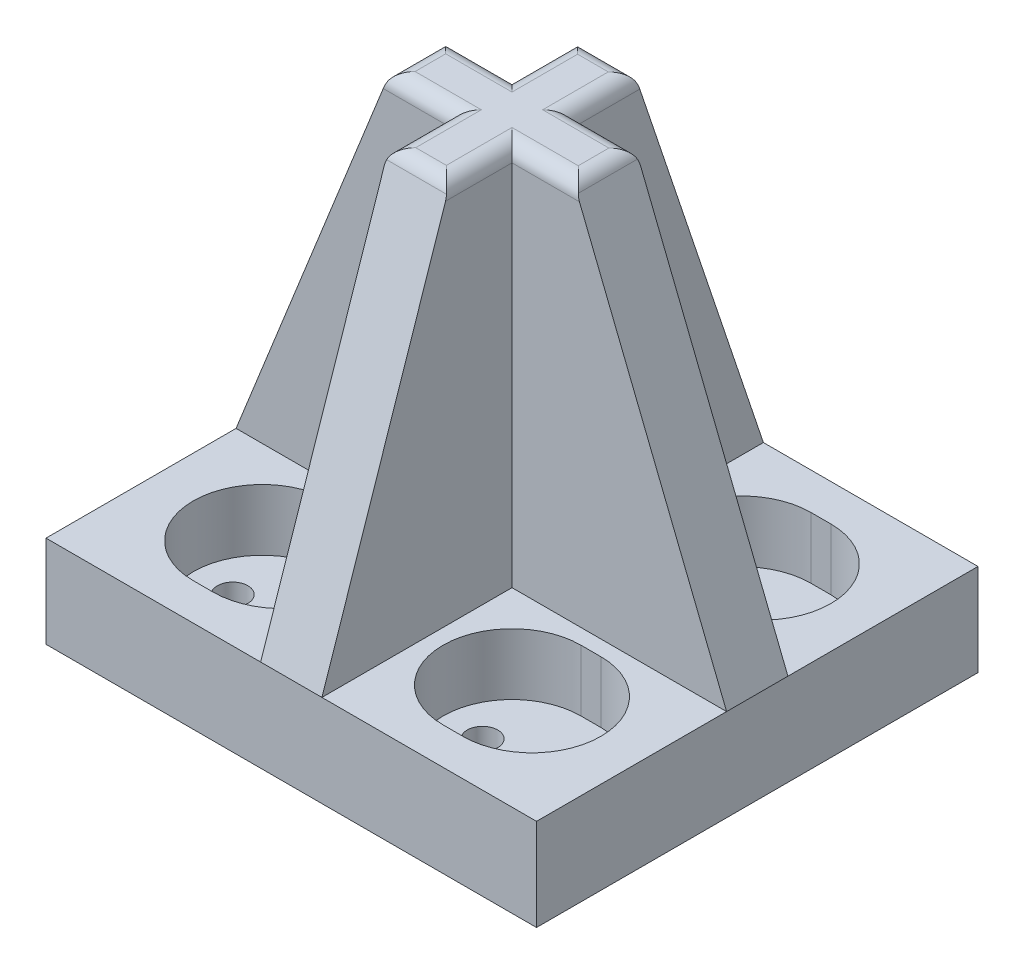
from build123d import *

# Parameters (mm, degrees)
SKETCH1_W                = 8
SKETCH1_H                = 7.2
BOSS_EXTRUDE1_DEPTH      = 3
CUT_EXTRUDE1_DEPTH       = 2
SKETCH3_R                = 0.49811532
CUT_EXTRUDE2_DEPTH       = 2
BOSS_EXTRUDE2_DEPTH      = 1
BOSS_EXTRUDE3_DEPTH      = 1
MIRROR22_COPY_1_SKETCH_W = 8
MIRROR22_COPY_1_SKETCH_H = 7.2
MIRROR22_COPY_1_DEPTH    = 3
MIRROR22_COPY_2_DEPTH    = 2
MIRROR22_COPY_3_SKETCH_R = 0.49811532
MIRROR22_COPY_3_DEPTH    = 2
MIRROR22_COPY_4_DEPTH    = 1
MIRROR22_COPY_5_DEPTH    = 1
MIRROR22_COPY_6_DEPTH    = 1
MIRROR22_COPY_7_DEPTH    = 1
FILLET6_R                = 0.5


with BuildPart() as part:
    # Sketch1 → Boss-Extrude1 (new body)
    with BuildSketch(Plane(origin=(0, 0, 0), x_dir=(1, 0, 0), z_dir=(0, 1, 0))):
        with Locations((4, -3.6)):
            Rectangle(SKETCH1_W, SKETCH1_H)
    boss_extrude1 = extrude(amount=BOSS_EXTRUDE1_DEPTH)

    # Sketch2 → Cut-Extrude1 (cut)
    with BuildSketch(Plane(origin=(0, 3, 0), x_dir=(1, 0, 0), z_dir=(0, 1, 0))):
        with BuildLine():
            Line((3.75, -1.5), (4.4, -1.5))
            ThreePointArc((4.4, -1.5), (6.65, -3.75), (4.4, -6))
            Line((4.4, -6), (3.75, -6))
            ThreePointArc((3.75, -6), (1.5, -3.75), (3.75, -1.5))
        make_face()
    cut_extrude1 = extrude(amount=-CUT_EXTRUDE1_DEPTH, mode=Mode.SUBTRACT)

    # Sketch3 → Cut-Extrude2 (cut, through all)
    with BuildSketch(Plane(origin=(0, 1, 0), x_dir=(1, 0, 0), z_dir=(0, 1, 0))):
        with Locations((2.7875, -3.75)):
            Circle(SKETCH3_R)
        with Locations((5.3625, -3.75)):
            Circle(SKETCH3_R)
    cut_extrude2 = extrude(amount=-CUT_EXTRUDE2_DEPTH, mode=Mode.SUBTRACT)

    # Sketch4 → Boss-Extrude2 (add)
    with BuildSketch(Plane.ZY):
        Polygon((0, 3), (0, 15.5), (3, 15.5), (7.2, 3), align=None)
    boss_extrude2 = extrude(amount=-BOSS_EXTRUDE2_DEPTH)

    # Sketch7 → Boss-Extrude3 (add)
    with BuildSketch(Plane(origin=(0, 0, 0), x_dir=(-1, 0, 0), z_dir=(0, 0, -1))):
        Polygon((0, 15.5), (-3, 15.5), (-8, 3), (0, 3), align=None)
    boss_extrude3 = extrude(amount=-BOSS_EXTRUDE3_DEPTH)

    # Mirror16: Boss-Extrude1, Cut-Extrude1, Cut-Extrude2, Boss-Extrude2, Boss-Extrude3 across plane
    add(boss_extrude1.mirror(Plane(origin=(0, 3, 0), x_dir=(0, 0, 1), z_dir=(1, 0, 0))))
    add(cut_extrude1.mirror(Plane(origin=(0, 3, 0), x_dir=(0, 0, 1), z_dir=(1, 0, 0))), mode=Mode.SUBTRACT)
    add(cut_extrude2.mirror(Plane(origin=(0, 3, 0), x_dir=(0, 0, 1), z_dir=(1, 0, 0))), mode=Mode.SUBTRACT)
    add(boss_extrude2.mirror(Plane(origin=(0, 3, 0), x_dir=(0, 0, 1), z_dir=(1, 0, 0))))
    add(boss_extrude3.mirror(Plane(origin=(0, 3, 0), x_dir=(0, 0, 1), z_dir=(1, 0, 0))))

    # Mirror21: Boss-Extrude1, Cut-Extrude1, Cut-Extrude2, Boss-Extrude2, Boss-Extrude3 across plane
    add(boss_extrude1.mirror(Plane(origin=(0, 3, 0), x_dir=(1, 0, 0), z_dir=(0, 0, 1))))
    add(cut_extrude1.mirror(Plane(origin=(0, 3, 0), x_dir=(1, 0, 0), z_dir=(0, 0, 1))), mode=Mode.SUBTRACT)
    add(cut_extrude2.mirror(Plane(origin=(0, 3, 0), x_dir=(1, 0, 0), z_dir=(0, 0, 1))), mode=Mode.SUBTRACT)
    add(boss_extrude2.mirror(Plane(origin=(0, 3, 0), x_dir=(1, 0, 0), z_dir=(0, 0, 1))))
    add(boss_extrude3.mirror(Plane(origin=(0, 3, 0), x_dir=(1, 0, 0), z_dir=(0, 0, 1))))

    # Mirror22: Boss-Extrude1, Cut-Extrude1, Cut-Extrude2 across plane
    add(boss_extrude1.mirror(Plane(origin=(0, 3, 0), x_dir=(0, 0, 1), z_dir=(-1, 0, 0))))
    add(cut_extrude1.mirror(Plane(origin=(0, 3, 0), x_dir=(0, 0, 1), z_dir=(-1, 0, 0))), mode=Mode.SUBTRACT)
    add(cut_extrude2.mirror(Plane(origin=(0, 3, 0), x_dir=(0, 0, 1), z_dir=(-1, 0, 0))), mode=Mode.SUBTRACT)

    # Mirror22 copy 1 sketch → Mirror22 copy 1 (add)
    with BuildSketch(Plane(origin=(0, 0, 0), x_dir=(-1, 0, 0), z_dir=(0, 1, 0))):
        with Locations((4, -3.6)):
            Rectangle(MIRROR22_COPY_1_SKETCH_W, MIRROR22_COPY_1_SKETCH_H)
    extrude(amount=MIRROR22_COPY_1_DEPTH)

    # Mirror22 copy 2 sketch → Mirror22 copy 2 (cut)
    with BuildSketch(Plane(origin=(0, 3, 0), x_dir=(-1, 0, 0), z_dir=(0, 1, 0))):
        with BuildLine():
            Line((3.75, -1.5), (4.4, -1.5))
            ThreePointArc((4.4, -1.5), (6.65, -3.75), (4.4, -6))
            Line((4.4, -6), (3.75, -6))
            ThreePointArc((3.75, -6), (1.5, -3.75), (3.75, -1.5))
        make_face()
    extrude(amount=-MIRROR22_COPY_2_DEPTH, mode=Mode.SUBTRACT)

    # Mirror22 copy 3 sketch → Mirror22 copy 3 (cut, through all)
    with BuildSketch(Plane(origin=(0, 1, 0), x_dir=(-1, 0, 0), z_dir=(0, 1, 0))):
        with Locations((2.7875, -3.75)):
            Circle(MIRROR22_COPY_3_SKETCH_R)
        with Locations((5.3625, -3.75)):
            Circle(MIRROR22_COPY_3_SKETCH_R)
    extrude(amount=-MIRROR22_COPY_3_DEPTH, mode=Mode.SUBTRACT)

    # Mirror22 copy 4 sketch → Mirror22 copy 4 (add)
    with BuildSketch(Plane(origin=(0, 0, 0), x_dir=(0, 0, -1), z_dir=(1, 0, 0))):
        Polygon((0, 3), (0, 15.5), (3, 15.5), (7.2, 3), align=None)
    extrude(amount=-MIRROR22_COPY_4_DEPTH)

    # Mirror22 copy 5 sketch → Mirror22 copy 5 (add)
    with BuildSketch(Plane.XY):
        Polygon((0, 15.5), (-3, 15.5), (-8, 3), (0, 3), align=None)
    extrude(amount=-MIRROR22_COPY_5_DEPTH)

    # Mirror22 copy 6 sketch → Mirror22 copy 6 (add)
    with BuildSketch(Plane(origin=(0, 0, 0), x_dir=(0, 0, 1), z_dir=(1, 0, 0))):
        Polygon((0, -3), (0, -15.5), (3, -15.5), (7.2, -3), align=None)
    extrude(amount=-MIRROR22_COPY_6_DEPTH)

    # Mirror22 copy 7 sketch → Mirror22 copy 7 (add)
    with BuildSketch(Plane(origin=(0, 0, 0), x_dir=(1, 0, 0), z_dir=(0, 0, -1))):
        Polygon((0, -15.5), (-3, -15.5), (-8, -3), (0, -3), align=None)
    extrude(amount=-MIRROR22_COPY_7_DEPTH)

    # Fillet6
    fillet6_edges = [part.edges().sort_by_distance(p)[0] for p in [
        (-1, 15.5, 2),
        (-2, 15.5, 1),
        (-3, 15.5, 0),
        (0, 15.5, -3),
        (1, 15.5, -2),
        (2, 15.5, -1),
        (-1, 15.5, -2),
        (-2, 15.5, -1),
        (1, 15.5, 2),
        (0, 15.5, 3),
        (2, 15.5, 1),
        (3, 15.5, 0),
    ]]
    fillet(fillet6_edges, radius=FILLET6_R)


solid = part.part
